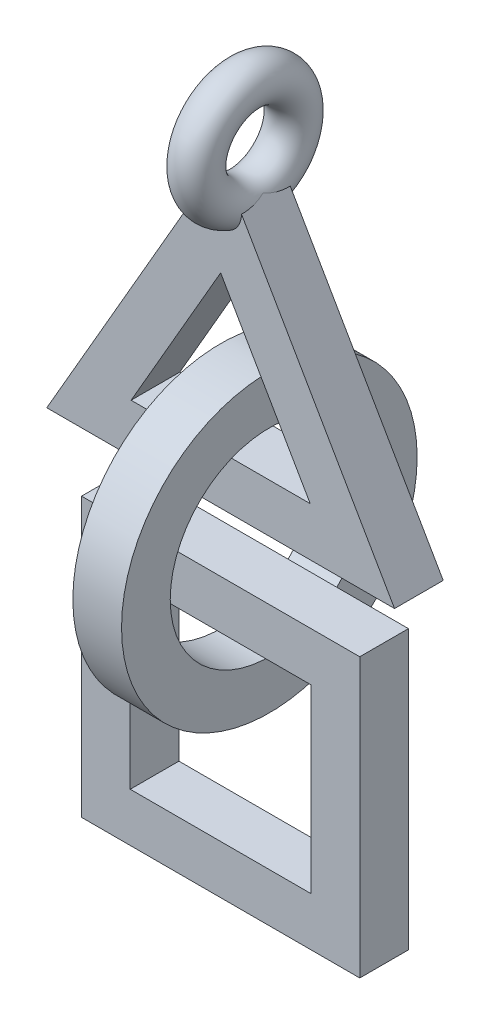
from build123d import *

# Parameters (mm, degrees)
BOSS_EXTRUDE1_DEPTH = 0.889
SKETCH2_R           = 5.3975
SKETCH2_R_2         = 3.6195
BOSS_EXTRUDE2_DEPTH = 0.889
SKETCH3_W           = 10.16
SKETCH3_H           = 10.16
SKETCH3_W_2         = 6.604
SKETCH3_H_2         = 6.604
BOSS_EXTRUDE3_DEPTH = 0.889
SKETCH4_R           = 0.762
BOSS_EXTRUDE4_START = -2.54
SKETCH8_R           = 0.00127
BOSS_EXTRUDE4_DEPTH = 18.999523


with BuildPart() as part:
    # Sketch1 → Boss-Extrude1 (new body, symmetric)
    with BuildSketch(Plane.XY):
        Polygon((0, 0), (-6.35, -10.998522628), (6.35, -10.998522628), align=None)
        Polygon((0, -3.556), (-3.270413664, -9.220522628), (3.270413664, -9.220522628), align=None, mode=Mode.SUBTRACT)
    extrude(amount=BOSS_EXTRUDE1_DEPTH, both=True)

    # Sketch4 → Revolve1 (revolve)
    with BuildSketch(Plane.XY):
        with Locations((0, -1.524)):
            Circle(SKETCH4_R)
    revolve(axis=Axis((0, 0.254, 0), (1, 0, 0)))

    # Sketch5 → Cut-Revolve1 (revolve, cut)
    with BuildSketch(Plane.XY):
        with BuildLine():
            Line((-0.659911358, -1.143), (-0.659911358, 0.254))
            Line((-0.659911358, 0.254), (0.659911358, 0.254))
            Line((0.659911358, 0.254), (0.659911358, -1.143))
            ThreePointArc((0.659911358, -1.143), (0, -0.762), (-0.659911358, -1.143))
        make_face()
    revolve(axis=Axis((0.659911358, 0.254, 0), (-1, 0, 0)), mode=Mode.SUBTRACT)



with BuildPart() as body_2:
    # Sketch2 → Boss-Extrude2 (new body, symmetric)
    with BuildSketch(Plane(origin=(0, 0, 0), x_dir=(0, 0, -1), z_dir=(1, 0, 0))):
        with Locations((0, -12.078022628)):
            Circle(SKETCH2_R)
        with Locations((0, -12.078022628)):
            Circle(SKETCH2_R_2, mode=Mode.SUBTRACT)
    extrude(amount=BOSS_EXTRUDE2_DEPTH, both=True)


with BuildPart() as body_3:
    # Sketch3 → Boss-Extrude3 (new body, symmetric)
    with BuildSketch(Plane.XY):
        with Locations((0, -18.237522628)):
            Rectangle(SKETCH3_W, SKETCH3_H)
        with Locations((0, -18.237522628)):
            Rectangle(SKETCH3_W_2, SKETCH3_H_2, mode=Mode.SUBTRACT)
    extrude(amount=BOSS_EXTRUDE3_DEPTH, both=True)


with BuildPart() as part_1:
    add(part.part)

    add(body_2.part)  # Boss-Extrude4 merges body 2

    add(body_3.part)  # Boss-Extrude4 merges body 3
    # Sketch8 → Boss-Extrude4 (add)
    with BuildSketch(Plane(origin=(0, 0, 0), x_dir=(1, 0, 0), z_dir=(0, 1, 0)).offset(BOSS_EXTRUDE4_START)):
        Circle(SKETCH8_R)
    extrude(amount=-BOSS_EXTRUDE4_DEPTH)


solid = part_1.part
